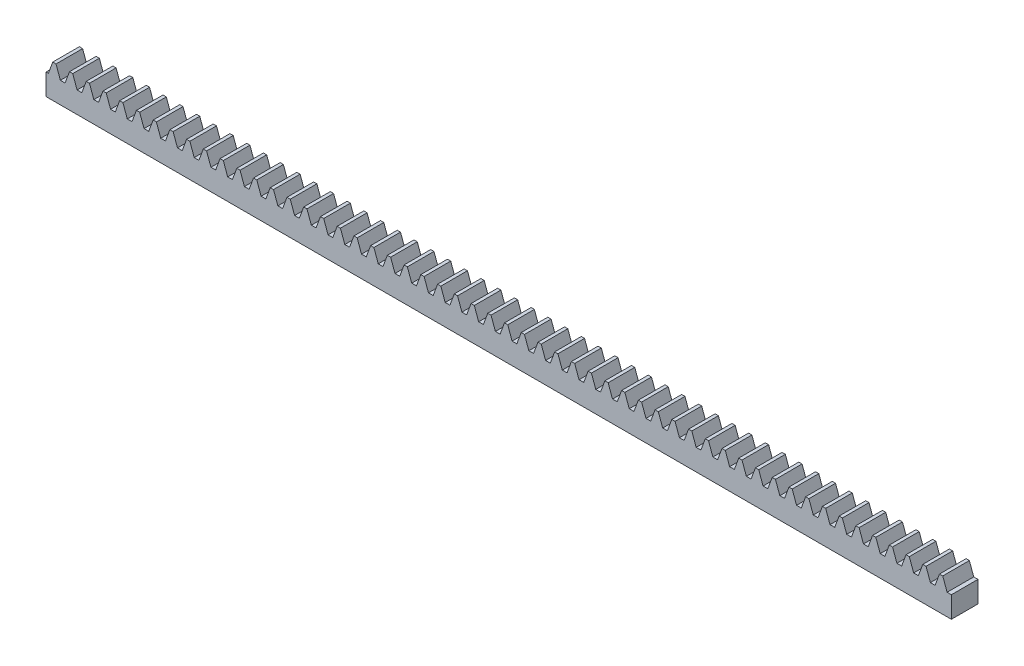
from build123d import *

# Parameters (mm, degrees)
BLANKSKE_W         = 170
BLANKSKE_H         = 6.25
BLANK_DEPTH        = 6
TOOTHCUTSIM_DEPTH  = 171.220628891
TEETHCUTS_COUNT    = 55
TEETHCUTS_PITCH    = 3.14159265
SKETCH1_W          = 1
SKETCH1_H          = 6.25
CUT_EXTRUDE1_DEPTH = 171.220628891


with BuildPart() as part:
    # BlankSke → Blank (new body)
    with BuildSketch(Plane.XY):
        with Locations((85, 3.125)):
            Rectangle(BLANKSKE_W, BLANKSKE_H)
    extrude(amount=-BLANK_DEPTH)

    # TooCutSkeSim → ToothCutSim (cut, through all)
    with BuildSketch(Plane.XY):
        Polygon((0.44443537, 4), (-0.44443537, 4), (-1.272613241, 6.2754), (1.272613241, 6.2754), align=None)
    toothcutsim = extrude(amount=-TOOTHCUTSIM_DEPTH, mode=Mode.SUBTRACT)

    # TeethCuts: ToothCutSim ×55
    with Locations(*[(i * TEETHCUTS_PITCH, 0, 0) for i in range(1, TEETHCUTS_COUNT)]):
        add(toothcutsim, mode=Mode.SUBTRACT)

    # Sketch1 → Cut-Extrude1 (cut, through all)
    with BuildSketch(Plane(origin=(170, 0, 0), x_dir=(0, 0, -1), z_dir=(1, 0, 0))):
        with Locations((0.5, 3.125)):
            Rectangle(SKETCH1_W, SKETCH1_H)
    extrude(amount=-CUT_EXTRUDE1_DEPTH, mode=Mode.SUBTRACT)


solid = part.part
